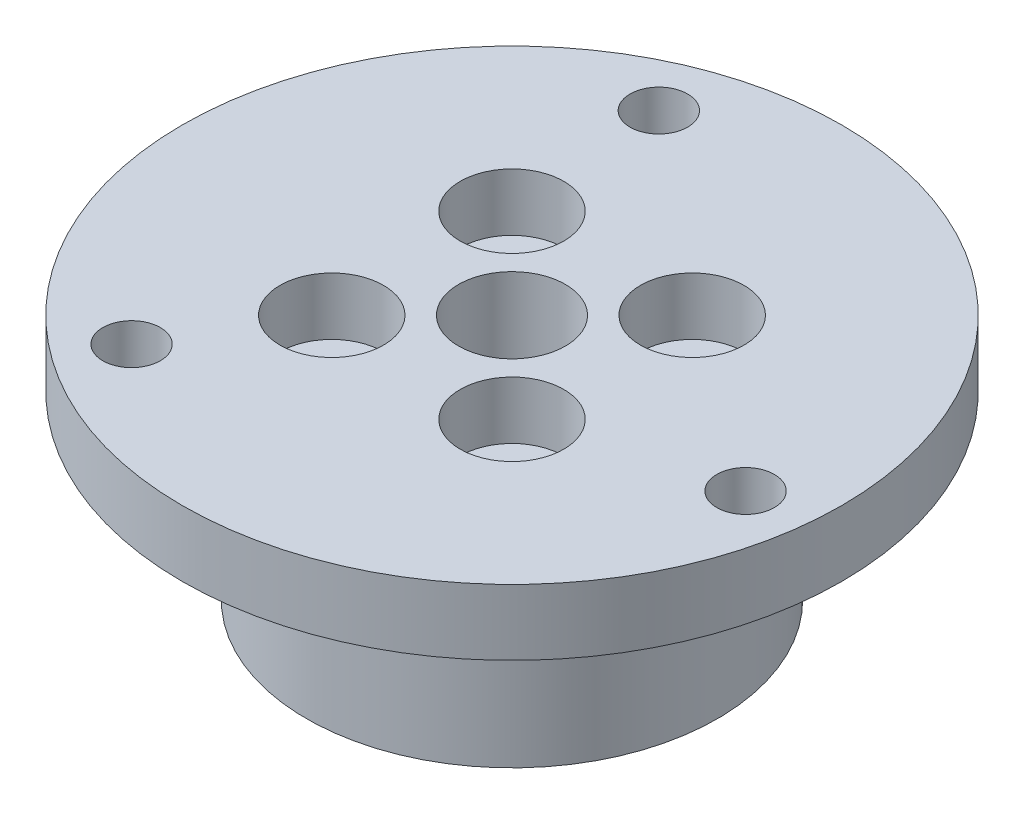
from build123d import *

# Parameters (mm, degrees)
SKETCH1_R      = 20.05
SKETCH1_R_2    = 3.25
SKETCH1_R_3    = 1.75
EXTRUDE1_DEPTH = 15
SKETCH7_R      = 3.15
EXTRUDE4_DEPTH = 3.5
SKETCH8_R      = 20.05
SKETCH8_R_2    = 12.5
EXTRUDE5_DEPTH = 11


with BuildPart() as part:
    # Sketch1 → Extrude1 (new body)
    with BuildSketch(Plane(origin=(0, 0, 0), x_dir=(1, 0, 0), z_dir=(0, 1, 0))):
        Circle(SKETCH1_R)
        Circle(SKETCH1_R_2, mode=Mode.SUBTRACT)
        with Locations((5.480077554, 5.480077554)):
            Circle(SKETCH1_R_3, mode=Mode.SUBTRACT)
        with Locations((5.480077554, -5.480077554)):
            Circle(SKETCH1_R_3, mode=Mode.SUBTRACT)
        with Locations((-5.480077554, -5.480077554)):
            Circle(SKETCH1_R_3, mode=Mode.SUBTRACT)
        with Locations((-5.480077554, 5.480077554)):
            Circle(SKETCH1_R_3, mode=Mode.SUBTRACT)
        with Locations((-10.044563579, -13.090330115)):
            Circle(SKETCH1_R_3, mode=Mode.SUBTRACT)
        with Locations((-6.314276634, 15.244012286)):
            Circle(SKETCH1_R_3, mode=Mode.SUBTRACT)
        with Locations((16.358840213, -2.153682172)):
            Circle(SKETCH1_R_3, mode=Mode.SUBTRACT)
    extrude(amount=EXTRUDE1_DEPTH)

    # Sketch7 → Extrude4 (cut)
    with BuildSketch(Plane(origin=(0, 15, 0), x_dir=(1, 0, 0), z_dir=(0, 1, 0))):
        with Locations((-5.480077554, 5.480077554)):
            Circle(SKETCH7_R)
        with Locations((5.480077554, 5.480077554)):
            Circle(SKETCH7_R)
        with Locations((5.480077554, -5.480077554)):
            Circle(SKETCH7_R)
        with Locations((-5.480077554, -5.480077554)):
            Circle(SKETCH7_R)
    extrude(amount=-EXTRUDE4_DEPTH, mode=Mode.SUBTRACT)

    # Sketch8 → Extrude5 (cut)
    with BuildSketch(Plane.XZ):
        Circle(SKETCH8_R)
        Circle(SKETCH8_R_2, mode=Mode.SUBTRACT)
    extrude(amount=-EXTRUDE5_DEPTH, mode=Mode.SUBTRACT)


solid = part.part
